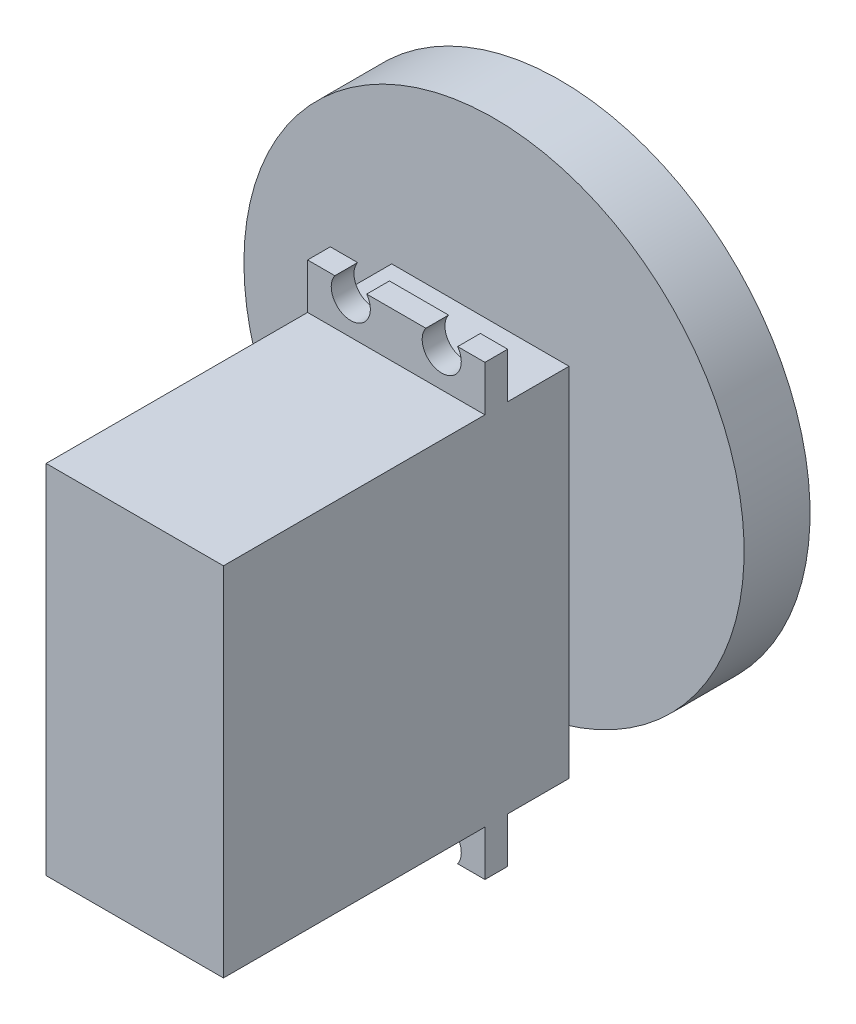
from build123d import *

# Parameters (mm, degrees)
SKETCH1_W           = 19.812
SKETCH1_H           = 39.878
BOSS_EXTRUDE1_DEPTH = 29.21
BOSS_EXTRUDE2_DEPTH = 2.54
SKETCH3_W           = 19.812
SKETCH3_H           = 39.878
BOSS_EXTRUDE3_DEPTH = 6.858
SKETCH4_R           = 6.35
BOSS_EXTRUDE4_DEPTH = 1.524
SKETCH9_R           = 27.94
SKETCH9_R_2         = 1.905
BOSS_EXTRUDE6_DEPTH = 7.366


with BuildPart() as part:
    # Sketch1 → Boss-Extrude1 (new body)
    with BuildSketch(Plane.XY):
        with Locations((9.906, 19.939)):
            Rectangle(SKETCH1_W, SKETCH1_H)
    extrude(amount=BOSS_EXTRUDE1_DEPTH)

    # Sketch2 → Boss-Extrude2 (add)
    with BuildSketch(Plane(origin=(0, 0, 0), x_dir=(-1, 0, 0), z_dir=(0, 0, -1))):
        with BuildLine():
            Line((0, -5.08), (-3.048725862, -5.08))
            ThreePointArc((-3.048725862, -5.08), (-4.826, -1.6256), (-6.603274138, -5.08))
            Line((-6.603274138, -5.08), (-13.208725862, -5.08))
            ThreePointArc((-13.208725862, -5.08), (-14.986, -1.6256), (-16.763274138, -5.08))
            Line((-16.763274138, -5.08), (-19.812, -5.08))
            Line((-19.812, -5.08), (-19.812, 44.958))
            Line((-19.812, 44.958), (-16.763274138, 44.958))
            ThreePointArc((-16.763274138, 44.958), (-14.986, 41.5036), (-13.208725862, 44.958))
            Line((-13.208725862, 44.958), (-6.603274138, 44.958))
            ThreePointArc((-6.603274138, 44.958), (-4.826, 41.5036), (-3.048725862, 44.958))
            Line((-3.048725862, 44.958), (0, 44.958))
            Line((0, 44.958), (0, -5.08))
        make_face()
    extrude(amount=BOSS_EXTRUDE2_DEPTH)

    # Sketch3 → Boss-Extrude3 (add)
    with BuildSketch(Plane(origin=(0, 0, -2.54), x_dir=(-1, 0, 0), z_dir=(0, 0, -1))):
        with Locations((-9.906, 19.939)):
            Rectangle(SKETCH3_W, SKETCH3_H)
    extrude(amount=BOSS_EXTRUDE3_DEPTH)

    # Sketch4 → Boss-Extrude4 (add)
    with BuildSketch(Plane(origin=(0, 0, -9.398), x_dir=(-1, 0, 0), z_dir=(0, 0, -1))):
        with Locations((-9.906, 30.226)):
            Circle(SKETCH4_R)
    extrude(amount=BOSS_EXTRUDE4_DEPTH)

    # Sketch9 → Boss-Extrude6 (add)
    with BuildSketch(Plane(origin=(0, 0, -10.922), x_dir=(-1, 0, 0), z_dir=(0, 0, -1))):
        with Locations((-9.906, 30.226)):
            Circle(SKETCH9_R)
        with Locations((-9.906, 30.226)):
            Circle(SKETCH9_R_2, mode=Mode.SUBTRACT)
    extrude(amount=BOSS_EXTRUDE6_DEPTH)


solid = part.part
